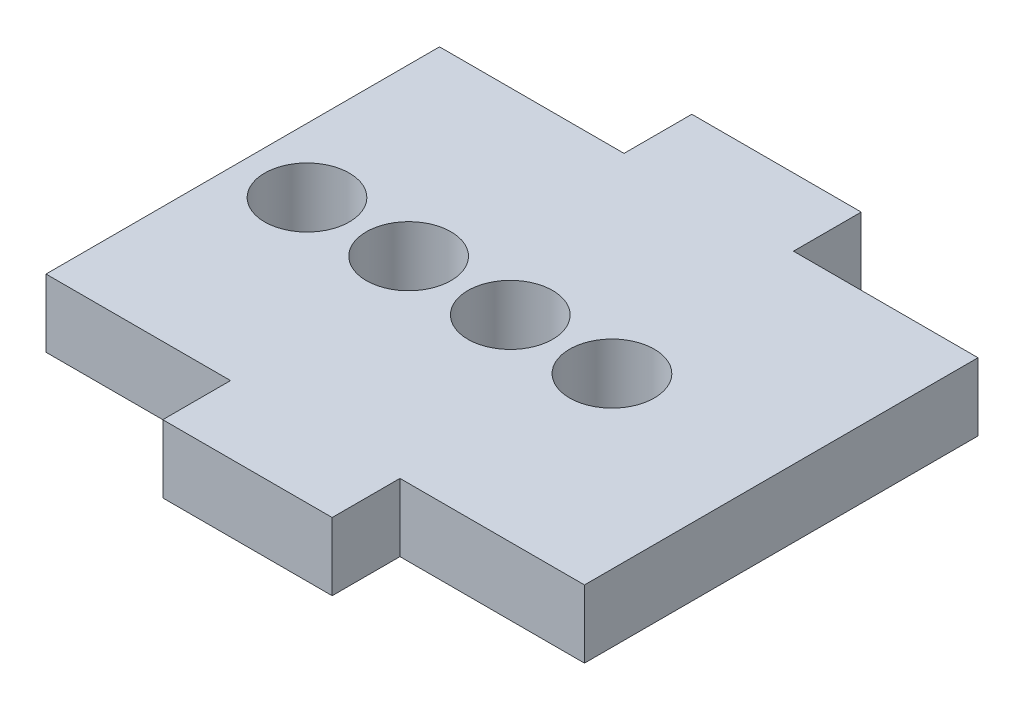
from build123d import *

# Parameters (mm, degrees)
SKETCH1_R           = 2.5
BOSS_EXTRUDE2_DEPTH = 4
SKETCH14_W          = 10
SKETCH14_H          = 4
BOSS_EXTRUDE5_DEPTH = 4
SKETCH15_W          = 10
SKETCH15_H          = 4
BOSS_EXTRUDE6_DEPTH = 4


with BuildPart() as part:
    # Sketch1 → Boss-Extrude2 (new body)
    with BuildSketch(Plane(origin=(0, 0, 0), x_dir=(1, 0, 0), z_dir=(0, 1, 0))):
        Polygon((36.786877756, 11.613831083), (44.492502068, 11.613831083), (44.492502068, -11.613831083), (36.786877756, -11.613831083), (27.518556454, -11.613831083), (12.70818574, -11.613831083), (12.70818574, 11.613831083), (27.518556454, 11.613831083), align=None)
        with Locations((16.5, 0)):
            Circle(SKETCH1_R, mode=Mode.SUBTRACT)
        with Locations((22.5, 0)):
            Circle(SKETCH1_R, mode=Mode.SUBTRACT)
        with Locations((28.5, 0)):
            Circle(SKETCH1_R, mode=Mode.SUBTRACT)
        with Locations((34.5, 0)):
            Circle(SKETCH1_R, mode=Mode.SUBTRACT)
    extrude(amount=BOSS_EXTRUDE2_DEPTH)

    # Sketch14 → Boss-Extrude5 (add)
    with BuildSketch(Plane.XY.offset(11.613831083)):
        with Locations((28.600343904, 2)):
            Rectangle(SKETCH14_W, SKETCH14_H)
    extrude(amount=BOSS_EXTRUDE5_DEPTH)

    # Sketch15 → Boss-Extrude6 (add)
    with BuildSketch(Plane(origin=(0, 0, -11.613831083), x_dir=(-1, 0, 0), z_dir=(0, 0, -1))):
        with Locations((-28.600343904, 2)):
            Rectangle(SKETCH15_W, SKETCH15_H)
    extrude(amount=BOSS_EXTRUDE6_DEPTH)


solid = part.part
